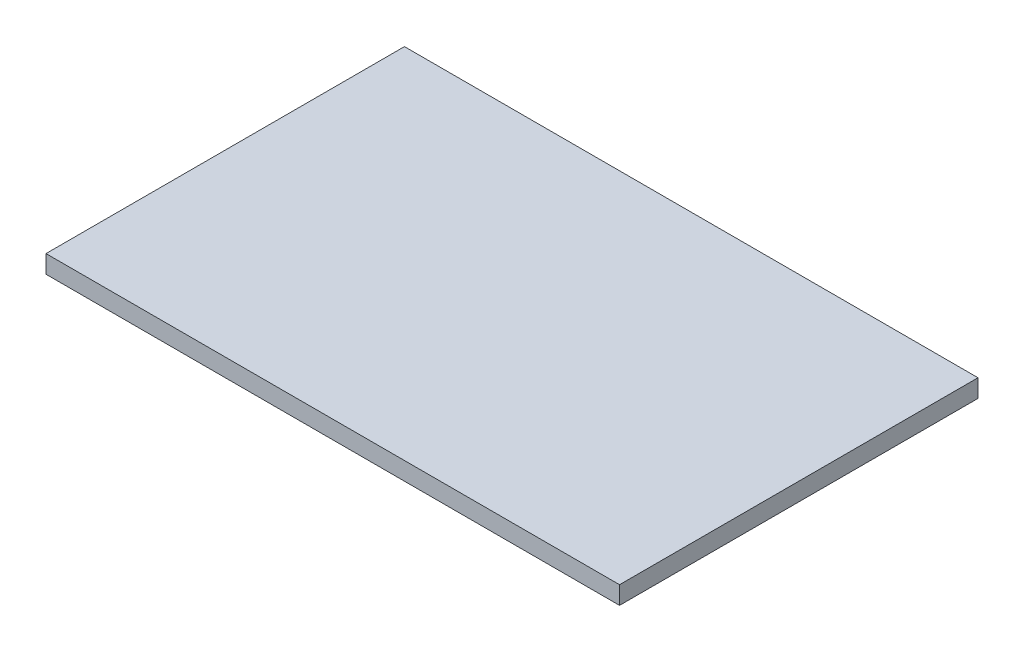
from build123d import *

# Parameters (mm, degrees)
SKETCH1_W           = 160
SKETCH1_H           = 100
BOSS_EXTRUDE1_DEPTH = 5


with BuildPart() as part:
    # Sketch1 → Boss-Extrude1 (new body)
    with BuildSketch(Plane(origin=(0, 0, 0), x_dir=(1, 0, 0), z_dir=(0, 1, 0))):
        with Locations((34.1545703, 27.992490011)):
            Rectangle(SKETCH1_W, SKETCH1_H)
    extrude(amount=BOSS_EXTRUDE1_DEPTH)


solid = part.part
